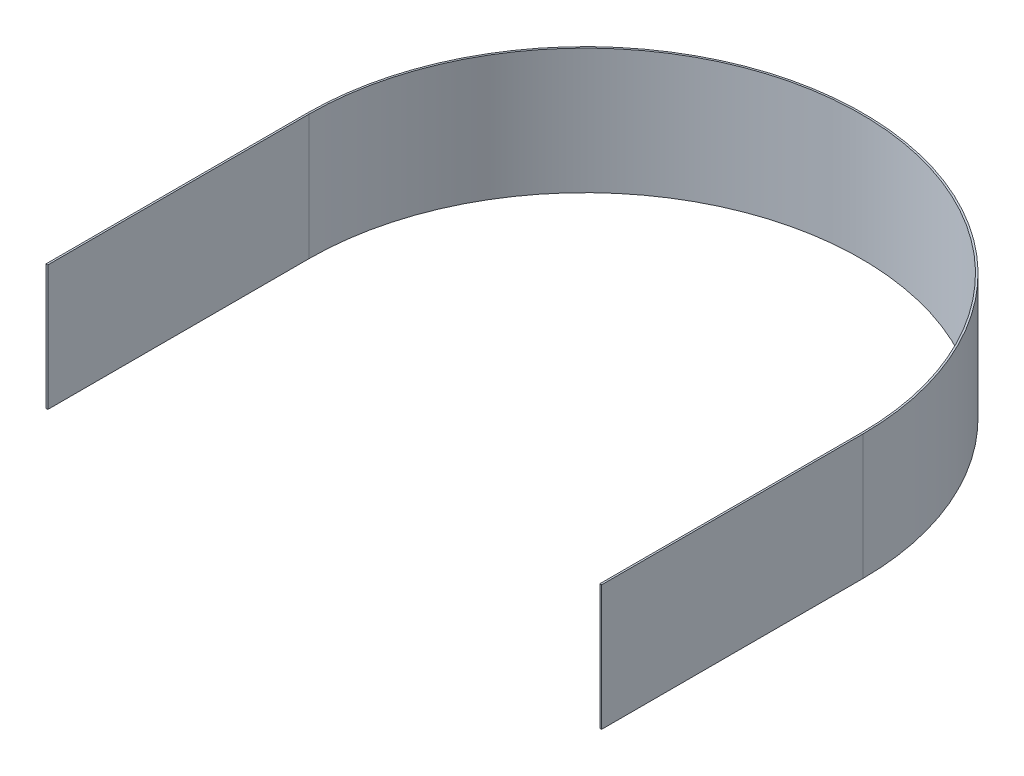
from build123d import *

# Parameters (mm, degrees)
BOSS_EXTRUDE1_DEPTH = 70


with BuildPart() as part:
    # Sketch1 → Boss-Extrude1 (new body)
    with BuildSketch(Plane(origin=(0, 0, 0), x_dir=(1, 0, 0), z_dir=(0, 1, 0))):
        with BuildLine():
            Line((-154.32837741, -146.032737518), (-155.32837741, -146.032737518))
            Line((-155.32837741, -146.032737518), (-155.32837741, 0))
            ThreePointArc((-155.32837741, 0), (0, 155.32837741), (155.32837741, 0))
            Line((155.32837741, 0), (155.32837741, -146.076270465))
            Line((155.32837741, -146.076270465), (154.32837741, -146.076270465))
            Line((154.32837741, -146.076270465), (154.32837741, 0))
            ThreePointArc((154.32837741, 0), (0, 154.32837741), (-154.32837741, 0))
            Line((-154.32837741, 0), (-154.32837741, -146.032737518))
        make_face()
    extrude(amount=BOSS_EXTRUDE1_DEPTH)


solid = part.part
